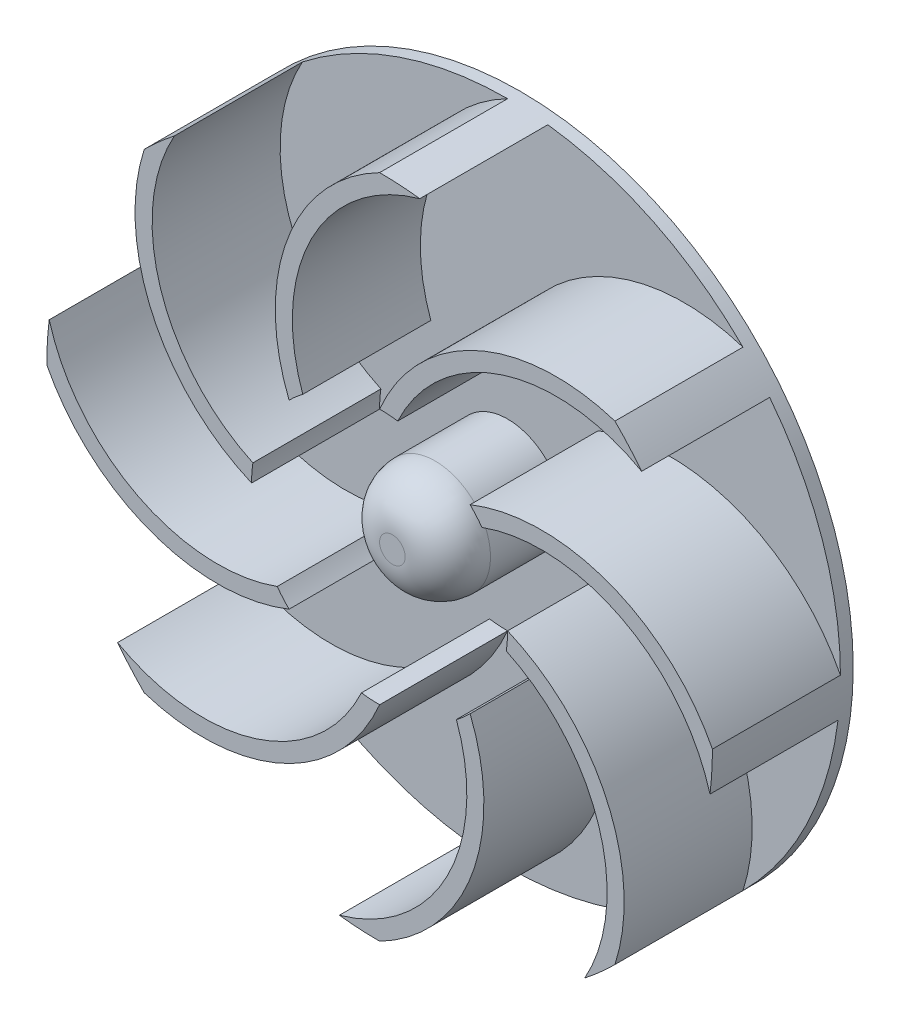
from build123d import *

# Parameters (mm, degrees)
BOSS_EXTRUDE1_DEPTH = 10
CIRPATTERN1_COUNT   = 8
SKETCH4_R           = 2.5
BOSS_EXTRUDE2_DEPTH = 11.83333333
SKETCH5_R           = 1.5
CUT_EXTRUDE1_DEPTH  = 10


with BuildPart() as part:
    # Sketch1 → Revolve2 (revolve)
    with BuildSketch(Plane(origin=(0, 0, 0), x_dir=(0, 0, -1), z_dir=(1, 0, 0))):
        with BuildLine():
            Line((0, 0), (0, 26))
            Line((0, 26), (-1, 26))
            Line((-1, 26), (-1, 4.333333333))
            Line((-1, 4.333333333), (-6.666666667, 4.333333333))
            ThreePointArc((-6.666666667, 4.333333333), (-9.023689271, 3.357022604), (-10, 1))
            Line((-10, 1), (-10, 0))
            Line((-10, 0), (0, 0))
        make_face()
    revolve(axis=Axis((0, 0, 10), (0, 0, -1)))

    # Sketch3 → Boss-Extrude1 (add)
    with BuildSketch(Plane.XY.offset(1)):
        with BuildLine():
            ThreePointArc((-5.998935548, 8.000798228), (-6.551514834, 7.554975406), (-7.071067812, 7.071067812))
            ThreePointArc((-7.071067812, 7.071067812), (-7.201026268, 17.904810567), (0, 26))
            ThreePointArc((0, 26), (1.573713281, 25.952329886), (3.141655863, 25.809494347))
            ThreePointArc((3.141655863, 25.809494347), (-5.308082056, 18.896330591), (-5.998935548, 8.000798228))
        make_face()
    boss_extrude1 = extrude(amount=BOSS_EXTRUDE1_DEPTH)

    # CirPattern1: Boss-Extrude1 ×8 about axis
    cirpattern1_axis = Axis((0, 0, 0), (0, 0, 1))
    for i in range(1, CIRPATTERN1_COUNT):
        add(boss_extrude1.rotate(cirpattern1_axis, i * 360 / CIRPATTERN1_COUNT))

    # Sketch4 → Boss-Extrude2 (add)
    with BuildSketch(Plane(origin=(0, 0, 0), x_dir=(-1, 0, 0), z_dir=(0, 0, -1))):
        Circle(SKETCH4_R)
    extrude(amount=BOSS_EXTRUDE2_DEPTH)

    # Sketch5 → Cut-Extrude1 (cut)
    with BuildSketch(Plane(origin=(0, 0, -11.83333333), x_dir=(-1, 0, 0), z_dir=(0, 0, -1))):
        Circle(SKETCH5_R)
    extrude(amount=-CUT_EXTRUDE1_DEPTH, mode=Mode.SUBTRACT)


solid = part.part
